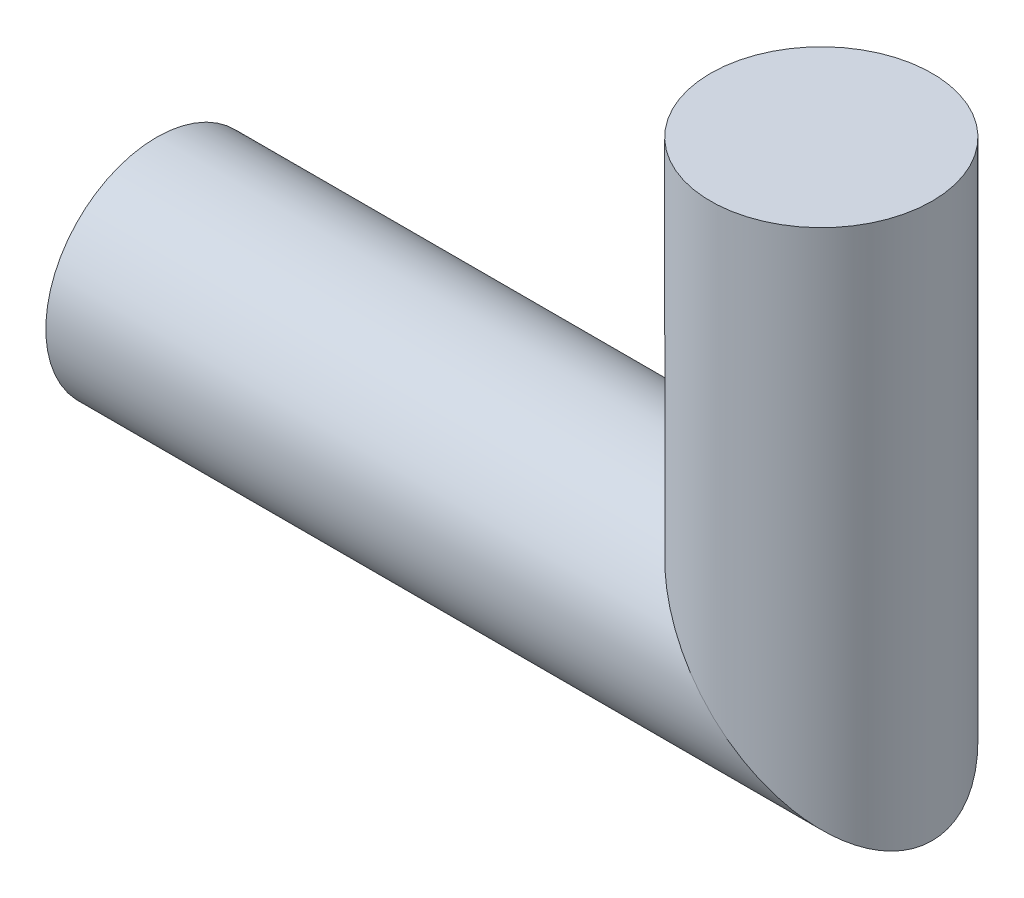
from build123d import *

# Parameters (mm, degrees)
SWEEP1_PROFILE_R   = 25.4
SKETCH9_R          = 12.7
CUT_EXTRUDE1_DEPTH = 25.4


with BuildPart() as part:
    # Sweep1: sweep along a path in Sketch2
    with BuildLine(Plane.XY) as sweep1_path:
        Line((0, 101.6), (0, 0))
        Line((0, 0), (-152.4, 0))
    # Sweep1 profile (on start of the path) → Sweep1 (sweep)
    with BuildSketch(Plane(origin=(0, 101.6, 0), x_dir=(0, 0, -1), z_dir=(0, -1, 0))):
        Circle(SWEEP1_PROFILE_R)
    sweep(path=sweep1_path.line, transition=Transition.RIGHT)

    # Sketch9 → Cut-Extrude1 (cut)
    with BuildSketch(Plane.ZY.offset(152.4)):
        Circle(SKETCH9_R)
    extrude(amount=-CUT_EXTRUDE1_DEPTH, mode=Mode.SUBTRACT)


solid = part.part
